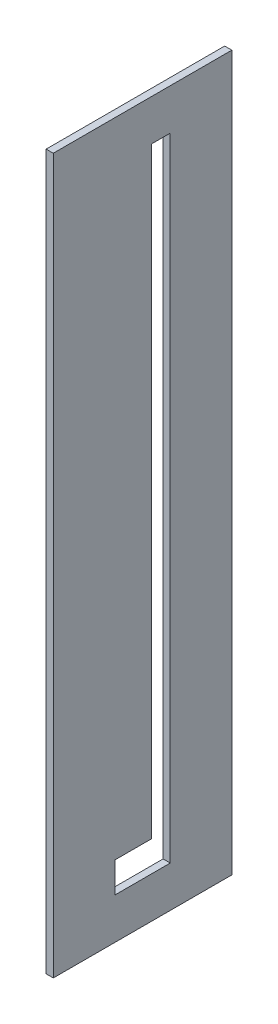
from build123d import *

# Parameters (mm, degrees)
SKETCH1_W           = 100
SKETCH1_H           = 400
SKETCH1_W_2         = 31
SKETCH1_H_2         = 354
BOSS_EXTRUDE1_DEPTH = 4
SKETCH2_W           = 20.5
SKETCH2_H           = 337
BOSS_EXTRUDE2_DEPTH = 4


with BuildPart() as part:
    # Sketch1 → Boss-Extrude1 (new body)
    with BuildSketch(Plane(origin=(0, 0, 0), x_dir=(0, 0, -1), z_dir=(1, 0, 0))):
        with Locations((0, 200)):
            Rectangle(SKETCH1_W, SKETCH1_H)
        with Locations((0, 200)):
            Rectangle(SKETCH1_W_2, SKETCH1_H_2, mode=Mode.SUBTRACT)
    extrude(amount=BOSS_EXTRUDE1_DEPTH)

    # Sketch2 → Boss-Extrude2 (add)
    with BuildSketch(Plane.ZY):
        with Locations((5.25, 208.5)):
            Rectangle(SKETCH2_W, SKETCH2_H)
    extrude(amount=-BOSS_EXTRUDE2_DEPTH)


solid = part.part
